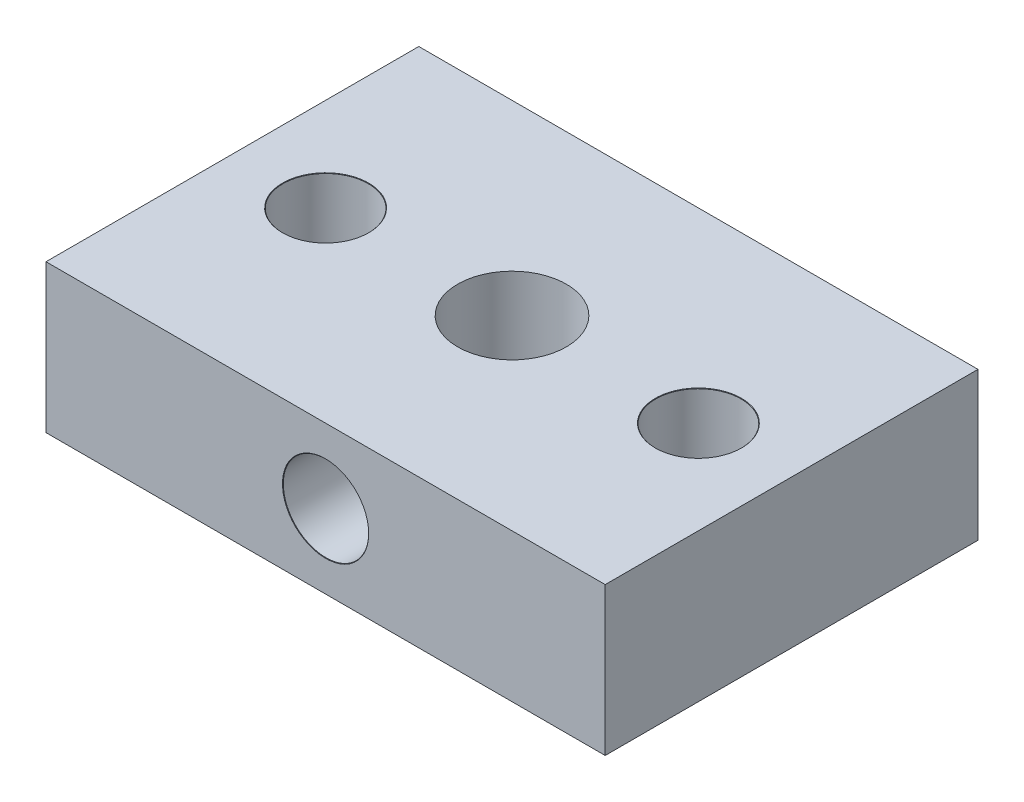
from build123d import *

# Parameters (mm, degrees)
SKETCH1_W                      = 36
SKETCH1_H                      = 24
SKETCH1_R                      = 3.5
BOSS_EXTRUDE1_DEPTH            = 9.53
M5_CLEARANCE_HOLE1_D           = 5.5
M5_CLEARANCE_HOLE1_DEPTH       = 13
M5_CLEARANCE_HOLE1_CSINK_D     = 5.55
M5_CLEARANCE_HOLE1_CSINK_ANGLE = 90
M5_CLEARANCE_HOLE1_TIP         = 1.652366702
M5_CLEARANCE_HOLE2_D           = 5.5
M5_CLEARANCE_HOLE2_DEPTH       = 13
M5_CLEARANCE_HOLE2_CSINK_D     = 5.55
M5_CLEARANCE_HOLE2_CSINK_ANGLE = 90
M5_CLEARANCE_HOLE2_TIP         = 1.652366702


with BuildPart() as part:
    # Sketch1 → Boss-Extrude1 (new body)
    with BuildSketch(Plane(origin=(0, 0, 0), x_dir=(1, 0, 0), z_dir=(0, 1, 0))):
        Rectangle(SKETCH1_W, SKETCH1_H)
        Circle(SKETCH1_R, mode=Mode.SUBTRACT)
    extrude(amount=BOSS_EXTRUDE1_DEPTH)

    # M5 Clearance Hole1
    with Locations(Plane.XY.offset(12)):
        with Locations((0, 4.765)):
            CounterSinkHole(M5_CLEARANCE_HOLE1_D / 2, M5_CLEARANCE_HOLE1_CSINK_D / 2, depth=M5_CLEARANCE_HOLE1_DEPTH, counter_sink_angle=M5_CLEARANCE_HOLE1_CSINK_ANGLE)
            with Locations((0, 0, -(M5_CLEARANCE_HOLE1_DEPTH + M5_CLEARANCE_HOLE1_TIP / 2))):  # 118° drill point
                Cone(0, M5_CLEARANCE_HOLE1_D / 2, M5_CLEARANCE_HOLE1_TIP, mode=Mode.SUBTRACT)

    # M5 Clearance Hole2
    with Locations(Plane(origin=(0, 9.53, 0), x_dir=(1, 0, 0), z_dir=(0, 1, 0))):
        with Locations((12, 0), (-12, 0)):
            CounterSinkHole(M5_CLEARANCE_HOLE2_D / 2, M5_CLEARANCE_HOLE2_CSINK_D / 2, depth=M5_CLEARANCE_HOLE2_DEPTH, counter_sink_angle=M5_CLEARANCE_HOLE2_CSINK_ANGLE)
            with Locations((0, 0, -(M5_CLEARANCE_HOLE2_DEPTH + M5_CLEARANCE_HOLE2_TIP / 2))):  # 118° drill point
                Cone(0, M5_CLEARANCE_HOLE2_D / 2, M5_CLEARANCE_HOLE2_TIP, mode=Mode.SUBTRACT)


solid = part.part
